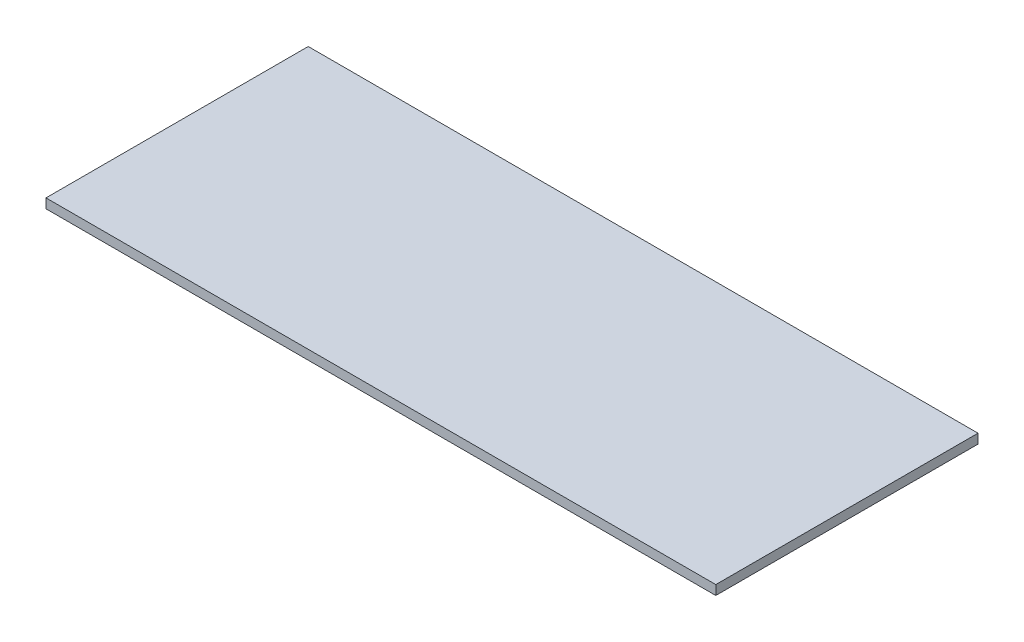
from build123d import *

# Parameters (mm, degrees)
SKETCH1_W           = 1346.2
SKETCH1_H           = 527.05
BOSS_EXTRUDE1_DEPTH = 19.05


with BuildPart() as part:
    # Sketch1 → Boss-Extrude1 (new body)
    with BuildSketch(Plane(origin=(0, 0, 0), x_dir=(1, 0, 0), z_dir=(0, 1, 0))):
        Rectangle(SKETCH1_W, SKETCH1_H)
    extrude(amount=BOSS_EXTRUDE1_DEPTH)


solid = part.part
